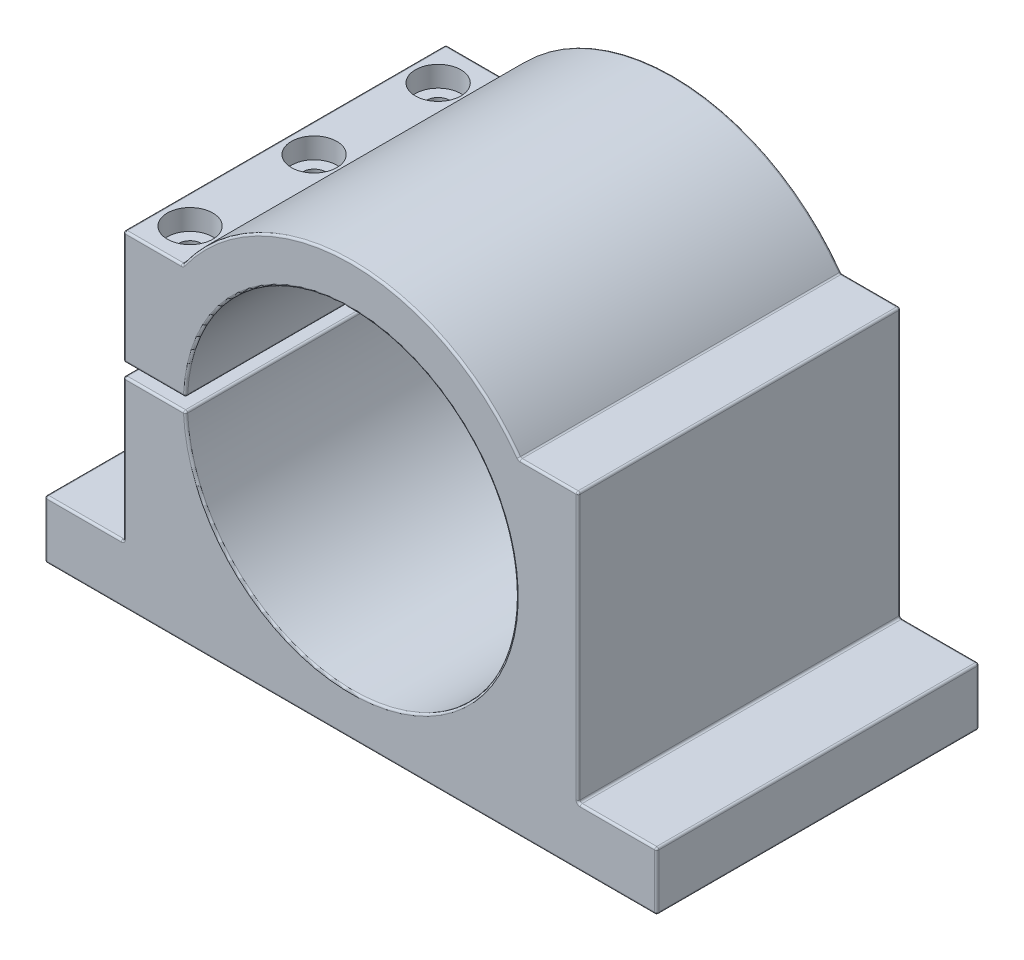
from build123d import *

# Parameters (mm, degrees)
EXTRUDE_1_DEPTH     = 39
SKETCH_2_R          = 5.5
CUT_EXTRUDE_1_DEPTH = 5
SKETCH_3_R          = 2.75
CUT_EXTRUDE_2_DEPTH = 25.5
SKETCH_4_R          = 2.1
CUT_EXTRUDE_3_DEPTH = 30
FILLET_1_R          = 0.5


with BuildPart() as part:
    # Эскиз1 → Бобышка-Вытянуть1 (new body, symmetric)
    with BuildSketch(Plane.XY):
        with BuildLine():
            Line((74, -50), (74, -36))
            Line((74, -36), (55, -36))
            Line((55, -36), (55, 29))
            Line((55, 29), (40.730823709, 29))
            ThreePointArc((40.730823709, 29), (0, 50), (-40.730823709, 29))
            Line((-40.730823709, 29), (-55, 29))
            Line((-55, 29), (-55, 1.5))
            Line((-55, 1.5), (-39.971865105, 1.5))
            ThreePointArc((-39.971865105, 1.5), (40, 0), (-39.971865105, -1.5))
            Line((-39.971865105, -1.5), (-55, -1.5))
            Line((-55, -1.5), (-55, -36))
            Line((-55, -36), (-74, -36))
            Line((-74, -36), (-74, -50))
            Line((-74, -50), (74, -50))
        make_face()
    extrude(amount=EXTRUDE_1_DEPTH, both=True)

    # Эскиз2 → Вырез-Вытянуть1 (cut)
    with BuildSketch(Plane(origin=(0, 29, 0), x_dir=(1, 0, 0), z_dir=(0, 1, 0))):
        with Locations((-47.865411854, 30)):
            Circle(SKETCH_2_R)
        with Locations((-47.865411854, 0)):
            Circle(SKETCH_2_R)
        with Locations((-47.865411854, -30)):
            Circle(SKETCH_2_R)
    extrude(amount=-CUT_EXTRUDE_1_DEPTH, mode=Mode.SUBTRACT)

    # Эскиз3 → Вырез-Вытянуть2 (cut)
    with BuildSketch(Plane(origin=(0, 24, 0), x_dir=(1, 0, 0), z_dir=(0, 1, 0))):
        with Locations((-47.865411854, 30)):
            Circle(SKETCH_3_R)
        with Locations((-47.865411854, 0)):
            Circle(SKETCH_3_R)
        with Locations((-47.865411854, -30)):
            Circle(SKETCH_3_R)
    extrude(amount=-CUT_EXTRUDE_2_DEPTH, mode=Mode.SUBTRACT)

    # Эскиз4 → Вырез-Вытянуть3 (cut)
    with BuildSketch(Plane(origin=(0, -1.5, 0), x_dir=(1, 0, 0), z_dir=(0, 1, 0))):
        with Locations((-47.865411854, 30)):
            Circle(SKETCH_4_R)
        with Locations((-47.865411854, 0)):
            Circle(SKETCH_4_R)
        with Locations((-47.865411854, -30)):
            Circle(SKETCH_4_R)
    extrude(amount=-CUT_EXTRUDE_3_DEPTH, mode=Mode.SUBTRACT)

    # Скругление1
    fillet_1_edges = [part.edges().sort_by_distance(p)[0] for p in [
        (-47.865411854, 29, 39),
        (55, -3.5, -39),
        (64.5, -36, -39),
        (74, -43, -39),
        (0, -50, -39),
        (-55, 15.25, 39),
        (-74, -43, -39),
        (-64.5, -36, -39),
        (-55, -18.75, -39),
        (-47.485932553, -1.5, -39),
        (40, 0, -39),
        (-47.485932553, 1.5, -39),
        (-55, 15.25, -39),
        (-47.485932553, 1.5, 39),
        (-47.865411854, 29, -39),
        (0, 50, -39),
        (47.865411854, 29, -39),
        (40, 0, 39),
        (55, 29, 0),
        (55, -36, 0),
        (74, -36, 0),
        (74, -50, 0),
        (-74, -50, 0),
        (-74, -36, 0),
        (-55, -36, 0),
        (-55, -1.5, 0),
        (-39.971865105, -1.5, 0),
        (-39.971865105, 1.5, 0),
        (-55, 1.5, 0),
        (-55, 29, 0),
        (-40.730823709, 29, 0),
        (40.730823709, 29, 0),
        (-47.485932553, -1.5, 39),
        (-55, -18.75, 39),
        (-64.5, -36, 39),
        (47.865411854, 29, 39),
        (-74, -43, 39),
        (0, -50, 39),
        (74, -43, 39),
        (64.5, -36, 39),
        (55, -3.5, 39),
        (0, 50, 39),
    ]]
    fillet(fillet_1_edges, radius=FILLET_1_R)


solid = part.part
